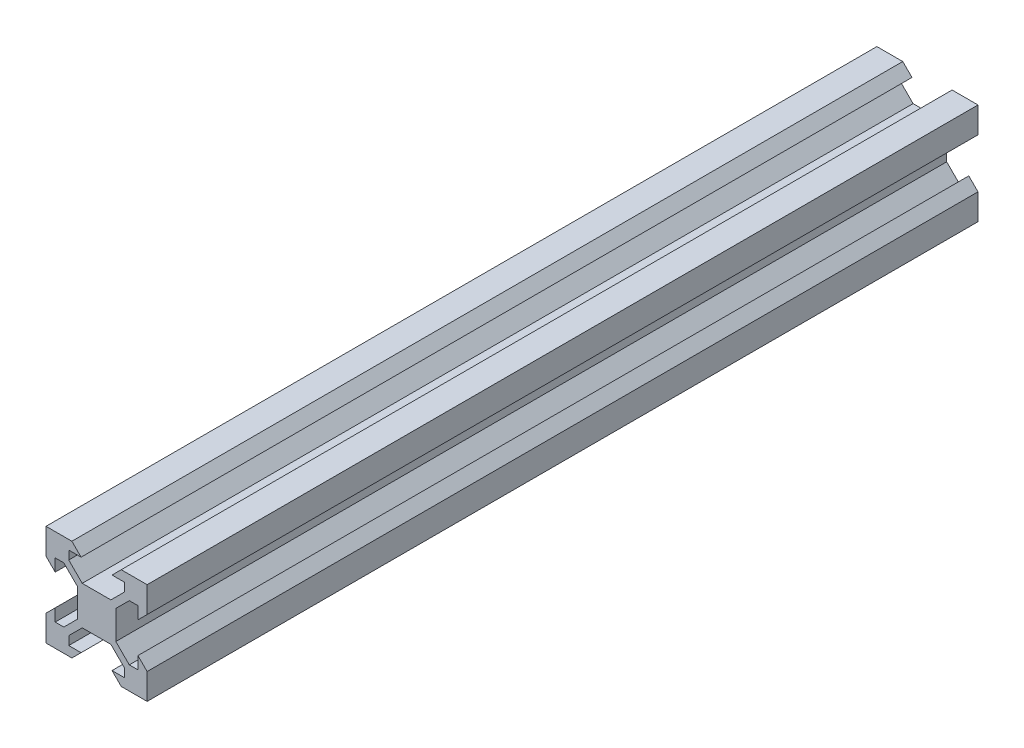
from build123d import *

# Parameters (mm, degrees)
SKETCH1_W           = 20
SKETCH1_H           = 20
BOSS_EXTRUDE1_DEPTH = 164.34
CUT_EXTRUDE1_DEPTH  = 165.34


with BuildPart() as part:
    # Sketch1 → Boss-Extrude1 (new body)
    with BuildSketch(Plane.XY):
        with Locations((10, 10)):
            Rectangle(SKETCH1_W, SKETCH1_H)
    extrude(amount=BOSS_EXTRUDE1_DEPTH)

    # Sketch2 → Cut-Extrude1 (cut, through all)
    with BuildSketch(Plane.XY.offset(164.34)):
        Polygon((4.5, 18.18), (6.94, 18.18), (5.12, 20), (14.88, 20), (13.06, 18.18), (15.5, 18.18), (15.5, 16.475807358), (12.834192642, 13.81), (7.165807358, 13.81), (4.5, 16.475807358), align=None)
        Polygon((14.88, 0), (13.06, 1.82), (15.5, 1.82), (15.5, 3.524192642), (12.834192642, 6.19), (7.165807358, 6.19), (4.5, 3.524192642), (4.5, 1.82), (6.94, 1.82), (5.12, 0), align=None)
        Polygon((1.82, 4.5), (1.82, 6.94), (0, 5.12), (0, 14.88), (1.82, 13.06), (1.82, 15.5), (3.524192642, 15.5), (6.19, 12.834192642), (6.19, 7.165807358), (3.524192642, 4.5), align=None)
        Polygon((20, 14.88), (18.18, 13.06), (18.18, 15.5), (16.475807358, 15.5), (13.81, 12.834192642), (13.81, 7.165807358), (16.475807358, 4.5), (18.18, 4.5), (18.18, 6.94), (20, 5.12), align=None)
    extrude(amount=-CUT_EXTRUDE1_DEPTH, mode=Mode.SUBTRACT)


solid = part.part
